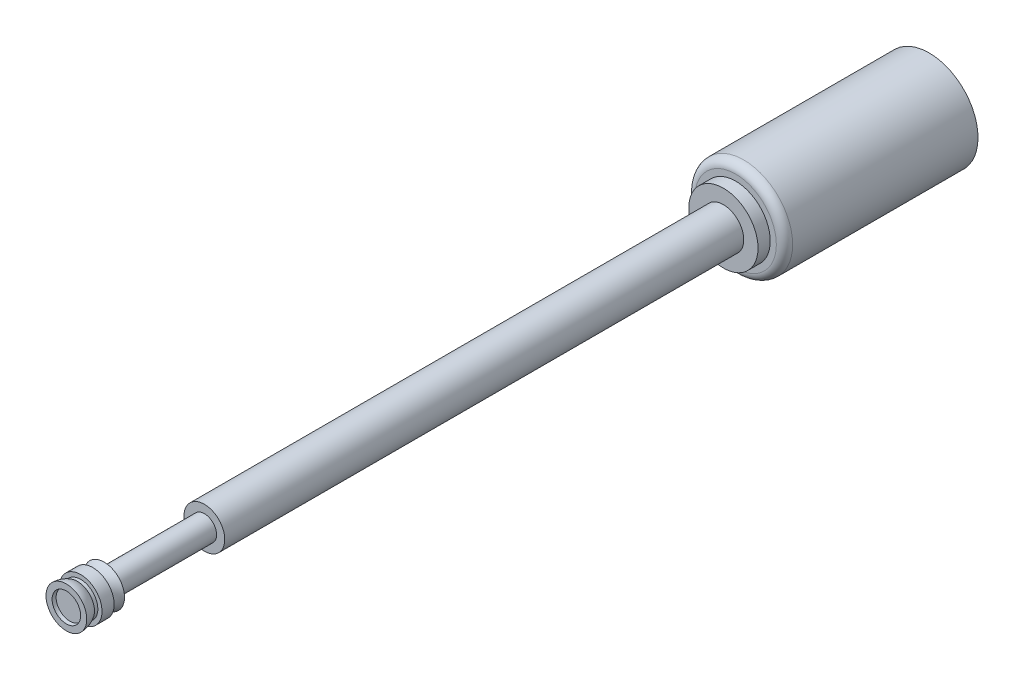
from build123d import *

# Parameters (mm, degrees)
SKETCH2_R           = 0.5
BOSS_EXTRUDE1_DEPTH = 15.5
SKETCH2_3_R         = 1.2
BOSS_EXTRUDE2_DEPTH = 4.75
FILLET1_R           = 0.2
SKETCH3_R           = 0.85
BOSS_EXTRUDE3_DEPTH = 0.3
SKETCH5_W           = 0.452483434
SKETCH5_H           = 0.029273323
SKETCH6_W           = 1.07619714
SKETCH6_H           = 2.46


with BuildPart() as part:
    # Sketch2 → Boss-Extrude1 (new body)
    with BuildSketch(Plane.XY):
        Circle(SKETCH2_R)
    extrude(amount=BOSS_EXTRUDE1_DEPTH)

    # Sketch2_3 → Boss-Extrude2 (add)
    with BuildSketch(Plane.XY):
        Circle(SKETCH2_3_R)
    extrude(amount=-BOSS_EXTRUDE2_DEPTH)

    # Fillet1
    fillet1_edges = [part.edges().sort_by_distance(p)[0] for p in [
        (-1.2, 0, 0),
    ]]
    fillet(fillet1_edges, radius=FILLET1_R)

    # Sketch3 → Boss-Extrude3 (add)
    with BuildSketch(Plane.XY):
        Circle(SKETCH3_R)
    extrude(amount=BOSS_EXTRUDE3_DEPTH)

    # Sketch4 → Revolve1 (revolve)
    with BuildSketch(Plane(origin=(0, 0, 0), x_dir=(1, 0, 0), z_dir=(0, 1, 0))):
        with BuildLine():
            Line((0.5, -15.5), (0, -15.5))
            Line((0, -15.5), (0, -16.0775))
            ThreePointArc((0, -16.0775), (0.247487373, -16.180012627), (0.35, -16.4275))
            Line((0.35, -16.4275), (0.5, -16.4275))
            ThreePointArc((0.5, -16.4275), (0.479947408, -16.287319809), (0.421398056, -16.158383523))
            Line((0.421398056, -16.158383523), (0.421398056, -16.076439057))
            Line((0.421398056, -16.076439057), (0.523845222, -16.076439057))
            Line((0.523845222, -16.076439057), (0.523845222, -15.778410938))
            Line((0.523845222, -15.778410938), (0.421398056, -15.778410938))
            ThreePointArc((0.421398056, -15.778410938), (0.441425242, -15.633764027), (0.5, -15.5))
        make_face()
    revolve(axis=Axis((0, 0, 15.5), (0, 0, 1)))

    # Sketch5 → Revolve2 (revolve)
    with BuildSketch(Plane(origin=(0, 0, 0), x_dir=(1, 0, 0), z_dir=(0, 1, 0))):
        with Locations((-0.226241717, -16.325363339)):
            Rectangle(SKETCH5_W, SKETCH5_H)
    revolve(axis=Axis((0, 0, 15.5), (0, 0, 1)))

    # Sketch6 → Cut-Revolve1 (revolve, cut)
    with BuildSketch(Plane(origin=(0, 0, 0), x_dir=(1, 0, 0), z_dir=(0, 1, 0))):
        with Locations((-0.83809857, -14.27)):
            Rectangle(SKETCH6_W, SKETCH6_H)
    revolve(axis=Axis((0, 0, 15.5), (0, 0, 1)), mode=Mode.SUBTRACT)


solid = part.part
